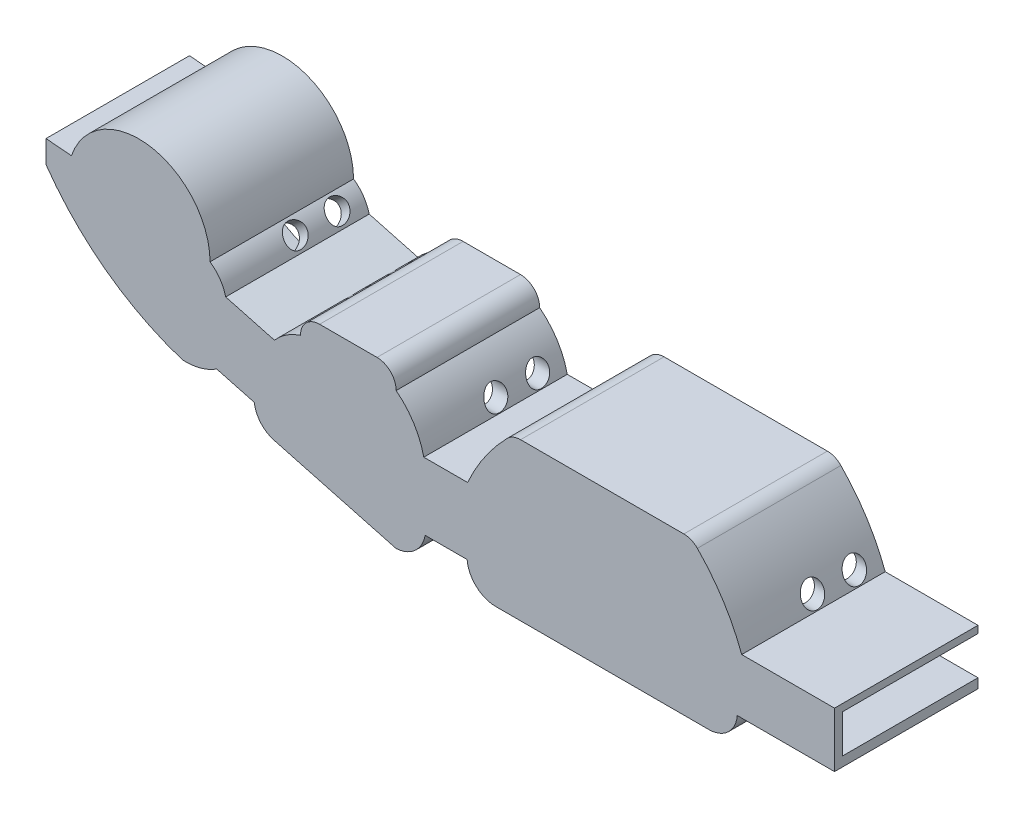
from build123d import *

# Parameters (mm, degrees)
WALLS_DEPTH                         = 16
BASE_DEPTH                          = 1
CUT_EXTRUDE2_REACH                  = 71.681
CUT_EXTRUDE2_END_RADIUS             = 7.978898039
SKETCH14_R                          = 1.4
CUT_EXTRUDE3_REACH                  = 95.244
CUT_EXTRUDE3_END_RADIUS             = 7.978898039
SKETCH15_R                          = 1.4
CUT_EXTRUDE4_REACH                  = 77.904
CUT_EXTRUDE4_END_RADIUS             = 33.443931457
SKETCH16_R                          = 1.4
CUT_EXTRUDE4_DIRECTION_2_REACH      = 77.904
CUT_EXTRUDE4_DIRECTION_2_END_RADIUS = 4.849339701
CUT_EXTRUDE5_REACH                  = 75.034
CUT_EXTRUDE5_END_RADIUS             = 6.135740623
SKETCH18_R                          = 1.4
CUT_EXTRUDE6_DEPTH                  = 1
CUT_EXTRUDE7_START                  = 1
SKETCH20_W                          = 0.5
SKETCH20_H                          = 5.968950485
CUT_EXTRUDE7_DEPTH                  = 13
CUT_EXTRUDE8_START                  = -1
SKETCH21_W                          = 1.2
SKETCH21_H                          = 4.8
CUT_EXTRUDE8_DEPTH                  = 17
BOSS_EXTRUDE7_DEPTH                 = 1


with BuildPart() as part:
    # Sketch1 → Walls (new body)
    with BuildSketch(Plane.XY):
        with BuildLine():
            Line((-89.425677347, 15.217392614), (-89.425677347, 12.385824824))
            ThreePointArc((-89.425677347, 12.385824824), (-81.906348322, 4.663063574), (-72.321084045, -0.266851135))
            ThreePointArc((-72.321084045, -0.266851135), (-70.074490708, -0.03182968), (-68.009952013, 0.884738205))
            Line((-68.009952013, 0.884738205), (-65.712719989, 0.268240269))
            Line((-65.712719989, 0.268240269), (-63.305171624, -0.377862773))
            ThreePointArc((-63.305171624, -0.377862773), (-62.413521198, -2.28542285), (-60.579036899, -3.319102342))
            Line((-60.579036899, -3.319102342), (-45.512163448, -7.362532125))
            ThreePointArc((-45.512163448, -7.362532125), (-43.123330152, -6.369383775), (-41.872204411, -4.104973799))
            Line((-41.872204411, -4.104973799), (-36.601206151, -4.104973799))
            ThreePointArc((-36.601206151, -4.104973799), (-35.453550113, -6.460513587), (-33.012978021, -7.414080542))
            Line((-33.012978021, -7.414080542), (-6.302454756, -7.414080542))
            ThreePointArc((-6.302454756, -7.414080542), (-3.861882663, -6.460513587), (-2.714226626, -4.104973799))
            Line((-2.714226626, -4.104973799), (9.481662569, -4.104973799))
            Line((9.481662569, -4.104973799), (9.481662569, 2.795026201))
            Line((9.481662569, 2.795026201), (-2.157765014, 2.795026201))
            ThreePointArc((-2.157765014, 2.795026201), (-4.475421171, 7.467506564), (-7.720187416, 11.551021571))
            ThreePointArc((-7.720187416, 11.551021571), (-8.494484922, 12.081481284), (-9.414311331, 12.268145448))
            Line((-9.414311331, 12.268145448), (-29.896800773, 12.268145448))
            ThreePointArc((-29.896800773, 12.268145448), (-30.816627182, 12.081481284), (-31.590924688, 11.551021571))
            ThreePointArc((-31.590924688, 11.551021571), (-34.39010211, 8.144207478), (-36.540818273, 4.295026201))
            Line((-36.540818273, 4.295026201), (-42.038103823, 4.295026201))
            ThreePointArc((-42.038103823, 4.295026201), (-43.288812463, 7.352239347), (-45.503987198, 9.802509784))
            ThreePointArc((-45.503987198, 9.802509784), (-46.206930923, 11.499566059), (-47.903987198, 12.202509784))
            Line((-47.903987198, 12.202509784), (-55.103987198, 12.202509784))
            ThreePointArc((-55.103987198, 12.202509784), (-56.801043473, 11.499566059), (-57.503987198, 9.802509784))
            ThreePointArc((-57.503987198, 9.802509784), (-59.284886069, 8.942613092), (-60.772674129, 7.63972791))
            Line((-60.772674129, 7.63972791), (-66.885187578, 9.280115945))
            ThreePointArc((-66.885187578, 9.280115945), (-67.605528448, 10.877592909), (-68.846606478, 12.114746473))
            ThreePointArc((-68.846606478, 12.114746473), (-76.342766302, 20.896236037), (-86.23721729, 14.945873803))
            Line((-86.23721729, 14.945873803), (-89.425677347, 15.217392614))
        make_face()
        with BuildLine():
            Line((-29.957941673, 10.657707986), (-29.654684343, 9.152027))
            Line((-29.654684343, 9.152027), (-29.354684343, 10.652027))
            Line((-29.354684343, 10.652027), (-28.654684343, 10.652027))
            Line((-28.654684343, 10.652027), (-28.354684343, 9.152027))
            Line((-28.354684343, 9.152027), (-28.054684343, 10.652027))
            Line((-28.054684343, 10.652027), (-27.354684343, 10.652027))
            Line((-27.354684343, 10.652027), (-27.054684343, 9.152027))
            Line((-27.054684343, 9.152027), (-26.754684343, 10.652027))
            Line((-26.754684343, 10.652027), (-26.054684343, 10.652027))
            Line((-26.054684343, 10.652027), (-25.754684343, 9.152027))
            Line((-25.754684343, 9.152027), (-25.454684343, 10.652027))
            Line((-25.454684343, 10.652027), (-24.754684343, 10.652027))
            Line((-24.754684343, 10.652027), (-24.454684343, 9.152027))
            Line((-24.454684343, 9.152027), (-24.154684343, 10.652027))
            Line((-24.154684343, 10.652027), (-23.454684343, 10.652027))
            Line((-23.454684343, 10.652027), (-23.154684343, 9.152027))
            Line((-23.154684343, 9.152027), (-22.854684343, 10.652027))
            Line((-22.854684343, 10.652027), (-22.154684343, 10.652027))
            Line((-22.154684343, 10.652027), (-21.854684343, 9.152027))
            Line((-21.854684343, 9.152027), (-21.554684343, 10.652027))
            Line((-21.554684343, 10.652027), (-20.854684343, 10.652027))
            Line((-20.854684343, 10.652027), (-20.554684343, 9.152027))
            Line((-20.554684343, 9.152027), (-20.254684343, 10.652027))
            Line((-20.254684343, 10.652027), (-19.554684343, 10.652027))
            Line((-19.554684343, 10.652027), (-19.254684343, 9.152027))
            Line((-19.254684343, 9.152027), (-18.954684343, 10.652027))
            Line((-18.954684343, 10.652027), (-18.254684343, 10.652027))
            Line((-18.254684343, 10.652027), (-17.954684343, 9.152027))
            Line((-17.954684343, 9.152027), (-17.654684343, 10.652027))
            Line((-17.654684343, 10.652027), (-16.954684343, 10.652027))
            Line((-16.954684343, 10.652027), (-16.654684343, 9.152027))
            Line((-16.654684343, 9.152027), (-16.354684343, 10.652027))
            Line((-16.354684343, 10.652027), (-15.654684343, 10.652027))
            Line((-15.654684343, 10.652027), (-15.354684343, 9.152027))
            Line((-15.354684343, 9.152027), (-15.054684343, 10.652027))
            Line((-15.054684343, 10.652027), (-14.354684343, 10.652027))
            Line((-14.354684343, 10.652027), (-14.054684343, 9.152027))
            Line((-14.054684343, 9.152027), (-13.754684343, 10.652027))
            Line((-13.754684343, 10.652027), (-13.080694354, 10.652027))
            Line((-13.080694354, 10.652027), (-12.780694354, 9.152027))
            Line((-12.780694354, 9.152027), (-12.480694354, 10.652027))
            Line((-12.480694354, 10.652027), (-11.780694354, 10.652027))
            Line((-11.780694354, 10.652027), (-11.480694354, 9.152027))
            Line((-11.480694354, 9.152027), (-11.180694354, 10.652027))
            Line((-11.180694354, 10.652027), (-10.506704364, 10.652027))
            Line((-10.506704364, 10.652027), (-10.206704364, 9.152027))
            Line((-10.206704364, 9.152027), (-9.906704364, 10.652027))
            Line((-9.906704364, 10.652027), (-9.353170431, 10.652027))
            ThreePointArc((-9.353170431, 10.652027), (-8.12308073, 9.896738229), (-7.34300907, 8.682213628))
            ThreePointArc((-7.34300907, 8.682213628), (-4.611558125, 5.76795929), (-3.634781843, 1.895026201))
            Line((-3.634781843, 1.895026201), (8.281662569, 1.895026201))
            Line((8.281662569, 1.895026201), (8.281662569, -2.904973799))
            Line((8.281662569, -2.904973799), (-3.718337431, -2.904973799))
            ThreePointArc((-3.718337431, -2.904973799), (-4.489094638, -5.239633694), (-6.746340048, -6.214080542))
            Line((-6.746340048, -6.214080542), (-32.569092729, -6.214080542))
            ThreePointArc((-32.569092729, -6.214080542), (-34.826338138, -5.239633694), (-35.597095345, -2.904973799))
            Line((-35.597095345, -2.904973799), (-43.623477835, -2.904973799))
            ThreePointArc((-43.623477835, -2.904973799), (-44.552537425, -4.937523747), (-46.570273024, -5.898332815))
            Line((-46.570273024, -5.898332815), (-59.1260009, -2.528807996))
            ThreePointArc((-59.1260009, -2.528807996), (-60.797180114, -1.501489359), (-61.420034751, 0.358692257))
            Line((-61.420034751, 0.358692257), (-69.260670014, 2.462848653))
            ThreePointArc((-69.260670014, 2.462848653), (-70.711197396, 1.000283853), (-72.762994505, 0.817926775))
            ThreePointArc((-72.762994505, 0.817926775), (-79.680116285, 4.137190402), (-85.38669117, 9.26545403))
            Line((-85.38669117, 9.26545403), (-88.684189776, 13.209190532))
            Line((-88.684189776, 13.209190532), (-88.684189776, 13.945331795))
            Line((-88.684189776, 13.945331795), (-88.29851244, 13.504674103))
            Line((-88.29851244, 13.504674103), (-86.640750005, 12.385824824))
            ThreePointArc((-86.640750005, 12.385824824), (-86.238180255, 12.562213326), (-85.831367356, 12.728582111))
            ThreePointArc((-85.831367356, 12.728582111), (-85.245352232, 14.777174034), (-84.141781559, 16.599884754))
            Line((-84.141781559, 16.599884754), (-83.841781559, 15.366152694))
            Line((-83.841781559, 15.366152694), (-83.541781559, 17.266152694))
            ThreePointArc((-83.541781559, 17.266152694), (-83.200039352, 17.586290744), (-82.840238881, 17.88599014))
            Line((-82.840238881, 17.88599014), (-82.540238881, 16.813922832))
            Line((-82.540238881, 16.813922832), (-82.240238881, 18.313922832))
            ThreePointArc((-82.240238881, 18.313922832), (-81.896217932, 18.524190844), (-81.542088231, 18.716947696))
            Line((-81.542088231, 18.716947696), (-81.242088231, 17.693779836))
            Line((-81.242088231, 17.693779836), (-80.942088231, 18.993779836))
            ThreePointArc((-80.942088231, 18.993779836), (-80.595255794, 19.127528905), (-80.2426118, 19.245103414))
            Line((-80.2426118, 19.245103414), (-79.9426118, 18.147652874))
            Line((-79.9426118, 18.147652874), (-79.6426118, 19.404765549))
            ThreePointArc((-79.6426118, 19.404765549), (-79.295091081, 19.474995797), (-78.944811991, 19.529836442))
            Line((-78.944811991, 19.529836442), (-78.644811991, 18.396857922))
            Line((-78.644811991, 18.396857922), (-78.344811991, 19.58746676))
            ThreePointArc((-78.344811991, 19.58746676), (-77.994297473, 19.600247924), (-77.64355905, 19.597729108))
            Line((-77.64355905, 19.597729108), (-77.34355905, 18.457829923))
            Line((-77.34355905, 18.457829923), (-77.04355905, 19.557829923))
            ThreePointArc((-77.04355905, 19.557829923), (-76.692411481, 19.513414143), (-76.34355905, 19.453586402))
            Line((-76.34355905, 19.453586402), (-76.04355905, 18.262977563))
            Line((-76.04355905, 18.262977563), (-75.74355905, 19.312977563))
            ThreePointArc((-75.74355905, 19.312977563), (-75.390953429, 19.207208521), (-75.04355905, 19.085409669))
            Line((-75.04355905, 19.085409669), (-74.74355905, 17.831277439))
            Line((-74.74355905, 17.831277439), (-74.44355905, 18.831277439))
            ThreePointArc((-74.44355905, 18.831277439), (-74.08894338, 18.652985458), (-73.74355905, 18.457409466))
            Line((-73.74355905, 18.457409466), (-73.44355905, 16.960277091))
            Line((-73.44355905, 16.960277091), (-73.14355905, 18.060277091))
            ThreePointArc((-73.14355905, 18.060277091), (-72.78549923, 17.783767154), (-72.44355905, 17.487555249))
            Line((-72.44355905, 17.487555249), (-72.14355905, 15.675519278))
            Line((-72.14355905, 15.675519278), (-71.84355905, 16.875519278))
            ThreePointArc((-71.84355905, 16.875519278), (-71.476987636, 16.427873033), (-71.14355905, 15.955023014))
            Line((-71.14355905, 15.955023014), (-70.84355905, 12.857560784))
            Line((-70.84355905, 12.857560784), (-70.54355905, 14.857560784))
            ThreePointArc((-70.54355905, 14.857560784), (-69.982359005, 13.084494169), (-69.84355905, 11.229920016))
            ThreePointArc((-69.84355905, 11.229920016), (-68.671585206, 9.985898204), (-68.118669602, 8.368679203))
            Line((-68.118669602, 8.368679203), (-60.392067832, 6.295125468))
            ThreePointArc((-60.392067832, 6.295125468), (-59.003259287, 7.752660176), (-57.217446594, 8.682213628))
            ThreePointArc((-57.217446594, 8.682213628), (-56.631660156, 10.096427191), (-55.217446594, 10.682213628))
            Line((-55.217446594, 10.682213628), (-55.133592914, 10.682178618))
            Line((-55.133592914, 10.682178618), (-54.833592914, 9.182178618))
            Line((-54.833592914, 9.182178618), (-54.533592914, 10.682178618))
            Line((-54.533592914, 10.682178618), (-53.833592914, 10.682178618))
            Line((-53.833592914, 10.682178618), (-53.533592914, 9.182178618))
            Line((-53.533592914, 9.182178618), (-53.233592914, 10.682178618))
            Line((-53.233592914, 10.682178618), (-52.533592914, 10.682178618))
            Line((-52.533592914, 10.682178618), (-52.233592914, 9.182178618))
            Line((-52.233592914, 9.182178618), (-51.933592914, 10.682178618))
            Line((-51.933592914, 10.682178618), (-51.259602924, 10.682178618))
            Line((-51.259602924, 10.682178618), (-50.959602924, 9.182178618))
            Line((-50.959602924, 9.182178618), (-50.659602924, 10.682178618))
            Line((-50.659602924, 10.682178618), (-49.959602924, 10.682178618))
            Line((-49.959602924, 10.682178618), (-49.659602924, 9.182178618))
            Line((-49.659602924, 9.182178618), (-49.359602924, 10.682178618))
            Line((-49.359602924, 10.682178618), (-49.217446594, 10.682213628))
            ThreePointArc((-49.217446594, 10.682213628), (-47.803233031, 10.096427191), (-47.217446594, 8.682213628))
            ThreePointArc((-47.217446594, 8.682213628), (-44.794291294, 6.284887251), (-43.592774814, 3.095026201))
            Line((-43.592774814, 3.095026201), (-35.592774814, 3.095026201))
            ThreePointArc((-35.592774814, 3.095026201), (-34.391258334, 6.284887251), (-31.968103034, 8.682213628))
            ThreePointArc((-31.968103034, 8.682213628), (-31.843038743, 9.372290059), (-31.483754411, 9.974586769))
            ThreePointArc((-31.483754411, 9.974586769), (-30.795920105, 10.483827589), (-29.957941673, 10.657707986))
        make_face(mode=Mode.SUBTRACT)
    extrude(amount=WALLS_DEPTH)

    # Sketch2 → Base (add)
    with BuildSketch(Plane(origin=(0, 0, 0), x_dir=(-1, 0, 0), z_dir=(0, 0, -1))):
        with BuildLine():
            Line((66.885187578, 9.280115945), (60.772674129, 7.63972791))
            ThreePointArc((60.772674129, 7.63972791), (59.284886069, 8.942613092), (57.503987198, 9.802509784))
            ThreePointArc((57.503987198, 9.802509784), (56.801043473, 11.499566059), (55.103987198, 12.202509784))
            Line((55.103987198, 12.202509784), (47.903987198, 12.202509784))
            ThreePointArc((47.903987198, 12.202509784), (46.206930923, 11.499566059), (45.503987198, 9.802509784))
            ThreePointArc((45.503987198, 9.802509784), (43.288812463, 7.352239347), (42.038103823, 4.295026201))
            Line((42.038103823, 4.295026201), (36.540818273, 4.295026201))
            ThreePointArc((36.540818273, 4.295026201), (34.39010211, 8.144207478), (31.590924688, 11.551021571))
            ThreePointArc((31.590924688, 11.551021571), (30.816627182, 12.081481284), (29.896800773, 12.268145448))
            Line((29.896800773, 12.268145448), (9.414311331, 12.268145448))
            ThreePointArc((9.414311331, 12.268145448), (8.494484922, 12.081481284), (7.720187416, 11.551021571))
            ThreePointArc((7.720187416, 11.551021571), (4.475421171, 7.467506564), (2.157765014, 2.795026201))
            Line((2.157765014, 2.795026201), (-9.481662569, 2.795026201))
            Line((-9.481662569, 2.795026201), (-9.481662569, -4.104973799))
            Line((-9.481662569, -4.104973799), (2.714226626, -4.104973799))
            ThreePointArc((2.714226626, -4.104973799), (3.861882663, -6.460513587), (6.302454756, -7.414080542))
            Line((6.302454756, -7.414080542), (33.012978021, -7.414080542))
            ThreePointArc((33.012978021, -7.414080542), (35.453550113, -6.460513587), (36.601206151, -4.104973799))
            Line((36.601206151, -4.104973799), (41.872204411, -4.104973799))
            ThreePointArc((41.872204411, -4.104973799), (43.123330152, -6.369383775), (45.512163448, -7.362532125))
            Line((45.512163448, -7.362532125), (60.579036899, -3.319102342))
            ThreePointArc((60.579036899, -3.319102342), (62.413521198, -2.28542285), (63.305171624, -0.377862773))
            Line((63.305171624, -0.377862773), (68.009952013, 0.884738205))
            ThreePointArc((68.009952013, 0.884738205), (70.074490708, -0.03182968), (72.321084045, -0.266851135))
            ThreePointArc((72.321084045, -0.266851135), (81.906348322, 4.663063574), (89.425677347, 12.385824824))
            Line((89.425677347, 12.385824824), (89.425677347, 15.217392614))
            Line((89.425677347, 15.217392614), (86.23721729, 14.945873803))
            ThreePointArc((86.23721729, 14.945873803), (76.342766302, 20.896236037), (68.846606478, 12.114746473))
            ThreePointArc((68.846606478, 12.114746473), (67.605528448, 10.877592909), (66.885187578, 9.280115945))
        make_face()
    extrude(amount=BASE_DEPTH)

    # Cut-Extrude2: up to this cylinder (the profile starts outside it)
    cut_extrude2_end = Plane(origin=(-27.697572731, 1.942377959, 4.875), z_dir=(0, 0, -1)) * Cylinder(CUT_EXTRUDE2_END_RADIUS, 165.569796077, mode=Mode.PRIVATE)
    # Sketch14 → Cut-Extrude2 (cut, up to the surface)
    with BuildSketch(Plane(origin=(-55, 0, 0), x_dir=(0, 0, -1), z_dir=(1, 0, 0)), mode=Mode.PRIVATE) as cut_extrude2_sk1:
        with Locations(Location((-2.25, 5.771124661, 0), (0, 0, 180))):
            Circle(SKETCH14_R)
    cut_extrude2_tool1 = extrude(cut_extrude2_sk1.sketch, amount=CUT_EXTRUDE2_REACH, mode=Mode.PRIVATE) - cut_extrude2_end
    add(cut_extrude2_tool1.solids().sort_by_distance((-55, 5.771125, 2.25))[0], mode=Mode.SUBTRACT)
    # Sketch14 → Cut-Extrude2 (cut, up to the surface)
    with BuildSketch(Plane(origin=(-55, 0, 0), x_dir=(0, 0, -1), z_dir=(1, 0, 0)), mode=Mode.PRIVATE) as cut_extrude2_sk2:
        with Locations(Location((-7.5, 5.771124661, 0), (0, 0, 180))):
            Circle(SKETCH14_R)
    cut_extrude2_tool2 = extrude(cut_extrude2_sk2.sketch, amount=CUT_EXTRUDE2_REACH, mode=Mode.PRIVATE) - cut_extrude2_end
    add(cut_extrude2_tool2.solids().sort_by_distance((-55, 5.771125, 7.5))[0], mode=Mode.SUBTRACT)

    # Cut-Extrude3: up to this cylinder (the profile starts outside it)
    cut_extrude3_end = Plane(origin=(-11.613539373, 1.942377959, 4.875), z_dir=(0, 0, -1)) * Cylinder(CUT_EXTRUDE3_END_RADIUS, 212.695796077, mode=Mode.PRIVATE)
    # Sketch15 → Cut-Extrude3 (cut, up to the surface)
    with BuildSketch(Plane(origin=(0, 0, 0), x_dir=(0, 0, -1), z_dir=(1, 0, 0)), mode=Mode.PRIVATE) as cut_extrude3_sk1:
        with Locations((-2.25, 4.295026201)):
            Circle(SKETCH15_R)
    cut_extrude3_tool1 = extrude(cut_extrude3_sk1.sketch, amount=-CUT_EXTRUDE3_REACH, mode=Mode.PRIVATE) - cut_extrude3_end
    add(cut_extrude3_tool1.solids().sort_by_distance((0, 4.295026, 2.25))[0], mode=Mode.SUBTRACT)
    # Sketch15 → Cut-Extrude3 (cut, up to the surface)
    with BuildSketch(Plane(origin=(0, 0, 0), x_dir=(0, 0, -1), z_dir=(1, 0, 0)), mode=Mode.PRIVATE) as cut_extrude3_sk2:
        with Locations((-7.5, 4.295026201)):
            Circle(SKETCH15_R)
    cut_extrude3_tool2 = extrude(cut_extrude3_sk2.sketch, amount=-CUT_EXTRUDE3_REACH, mode=Mode.PRIVATE) - cut_extrude3_end
    add(cut_extrude3_tool2.solids().sort_by_distance((0, 4.295026, 7.5))[0], mode=Mode.SUBTRACT)

    # Cut-Extrude4: up to this cylinder (the profile starts inside it)
    cut_extrude4_end = Plane(origin=(-62.017257268, 31.550246549, 4.875), z_dir=(0, 0, -1)) * Cylinder(CUT_EXTRUDE4_END_RADIUS, 228.945862914, mode=Mode.PRIVATE)
    # Sketch16 → Cut-Extrude4 (cut, up to the surface)
    with BuildSketch(Plane(origin=(-34.706485046, -29.099233606, 0), x_dir=(0, 0, -1), z_dir=(0.7662940611199278, 0.642490009177052, 0)), mode=Mode.PRIVATE) as cut_extrude4_sk1:
        with Locations(Location((-2.25, 51.800538809, 0), (0, 0, 90))):
            Circle(SKETCH16_R)
    cut_extrude4_tool1 = extrude(cut_extrude4_sk1.sketch, amount=-CUT_EXTRUDE4_REACH, mode=Mode.PRIVATE) & cut_extrude4_end
    add(cut_extrude4_tool1.solids().sort_by_distance((-67.987814, 10.595212, 2.25))[0], mode=Mode.SUBTRACT)
    # Sketch16 → Cut-Extrude4 (cut, up to the surface)
    with BuildSketch(Plane(origin=(-34.706485046, -29.099233606, 0), x_dir=(0, 0, -1), z_dir=(0.7662940611199278, 0.642490009177052, 0)), mode=Mode.PRIVATE) as cut_extrude4_sk2:
        with Locations(Location((-7.5, 51.800538809, 0), (0, 0, 90))):
            Circle(SKETCH16_R)
    cut_extrude4_tool2 = extrude(cut_extrude4_sk2.sketch, amount=-CUT_EXTRUDE4_REACH, mode=Mode.PRIVATE) & cut_extrude4_end
    add(cut_extrude4_tool2.solids().sort_by_distance((-67.987814, 10.595212, 7.5))[0], mode=Mode.SUBTRACT)

    # Cut-Extrude4 direction 2: up to this cylinder (the profile starts inside it)
    cut_extrude4_direction_2_end = Plane(origin=(-71.59328755, 8.118268196, 4.875), z_dir=(0, 0, -1)) * Cylinder(CUT_EXTRUDE4_DIRECTION_2_END_RADIUS, 171.756679402, mode=Mode.PRIVATE)
    # Sketch16 → Cut-Extrude4 direction 2 (cut, up to the surface)
    with BuildSketch(Plane(origin=(-34.706485046, -29.099233606, 0), x_dir=(0, 0, -1), z_dir=(0.7662940611199278, 0.642490009177052, 0)), mode=Mode.PRIVATE) as cut_extrude4_direction_2_sk1:
        with Locations(Location((-2.25, 51.800538809, 0), (0, 0, 90))):
            Circle(SKETCH16_R)
    cut_extrude4_direction_2_tool1 = extrude(cut_extrude4_direction_2_sk1.sketch, amount=CUT_EXTRUDE4_DIRECTION_2_REACH, mode=Mode.PRIVATE) & cut_extrude4_direction_2_end
    add(cut_extrude4_direction_2_tool1.solids().sort_by_distance((-67.987814, 10.595212, 2.25))[0], mode=Mode.SUBTRACT)
    # Sketch16 → Cut-Extrude4 direction 2 (cut, up to the surface)
    with BuildSketch(Plane(origin=(-34.706485046, -29.099233606, 0), x_dir=(0, 0, -1), z_dir=(0.7662940611199278, 0.642490009177052, 0)), mode=Mode.PRIVATE) as cut_extrude4_direction_2_sk2:
        with Locations(Location((-7.5, 51.800538809, 0), (0, 0, 90))):
            Circle(SKETCH16_R)
    cut_extrude4_direction_2_tool2 = extrude(cut_extrude4_direction_2_sk2.sketch, amount=CUT_EXTRUDE4_DIRECTION_2_REACH, mode=Mode.PRIVATE) & cut_extrude4_direction_2_end
    add(cut_extrude4_direction_2_tool2.solids().sort_by_distance((-67.987814, 10.595212, 7.5))[0], mode=Mode.SUBTRACT)

    # Cut-Extrude5: up to this cylinder (the profile starts outside it)
    cut_extrude5_end = Plane(origin=(-55.315764964, 2.84861097, 4.875), z_dir=(0, 0, -1)) * Cylinder(CUT_EXTRUDE5_END_RADIUS, 168.589481246, mode=Mode.PRIVATE)
    # Sketch18 → Cut-Extrude5 (cut, up to the surface)
    with BuildSketch(Plane(origin=(-56.106074928, 20.445624842, 0), x_dir=(0, 0, -1), z_dir=(-0.9395597001849875, 0.3423851191104788, 0)), mode=Mode.PRIVATE) as cut_extrude5_sk1:
        with Locations(Location((-2.25, 12.178466352, 0), (0, 0, 90))):
            Circle(SKETCH18_R)
    cut_extrude5_tool1 = extrude(cut_extrude5_sk1.sketch, amount=-CUT_EXTRUDE5_REACH, mode=Mode.PRIVATE) - cut_extrude5_end
    add(cut_extrude5_tool1.solids().sort_by_distance((-60.275801, 9.003229, 2.25))[0], mode=Mode.SUBTRACT)
    # Sketch18 → Cut-Extrude5 (cut, up to the surface)
    with BuildSketch(Plane(origin=(-56.106074928, 20.445624842, 0), x_dir=(0, 0, -1), z_dir=(-0.9395597001849875, 0.3423851191104788, 0)), mode=Mode.PRIVATE) as cut_extrude5_sk2:
        with Locations(Location((-7.5, 12.178466352, 0), (0, 0, 90))):
            Circle(SKETCH18_R)
    cut_extrude5_tool2 = extrude(cut_extrude5_sk2.sketch, amount=-CUT_EXTRUDE5_REACH, mode=Mode.PRIVATE) - cut_extrude5_end
    add(cut_extrude5_tool2.solids().sort_by_distance((-60.275801, 9.003229, 7.5))[0], mode=Mode.SUBTRACT)

    # Sketch19 → Cut-Extrude6 (cut)
    with BuildSketch(Plane.XY):
        with BuildLine():
            Line((-12.780694354, 9.152027), (-13.080694354, 10.652027))
            Line((-13.080694354, 10.652027), (-13.754684343, 10.652027))
            Line((-13.754684343, 10.652027), (-14.054684343, 9.152027))
            Line((-14.054684343, 9.152027), (-14.354684343, 10.652027))
            Line((-14.354684343, 10.652027), (-15.054684343, 10.652027))
            Line((-15.054684343, 10.652027), (-15.354684343, 9.152027))
            Line((-15.354684343, 9.152027), (-15.654684343, 10.652027))
            Line((-15.654684343, 10.652027), (-16.354684343, 10.652027))
            Line((-16.354684343, 10.652027), (-16.654684343, 9.152027))
            Line((-16.654684343, 9.152027), (-16.954684343, 10.652027))
            Line((-16.954684343, 10.652027), (-17.654684343, 10.652027))
            Line((-17.654684343, 10.652027), (-17.954684343, 9.152027))
            Line((-17.954684343, 9.152027), (-18.254684343, 10.652027))
            Line((-18.254684343, 10.652027), (-18.954684343, 10.652027))
            Line((-18.954684343, 10.652027), (-19.254684343, 9.152027))
            Line((-19.254684343, 9.152027), (-19.554684343, 10.652027))
            Line((-19.554684343, 10.652027), (-20.254684343, 10.652027))
            Line((-20.254684343, 10.652027), (-20.554684343, 9.152027))
            Line((-20.554684343, 9.152027), (-20.854684343, 10.652027))
            Line((-20.854684343, 10.652027), (-21.554684343, 10.652027))
            Line((-21.554684343, 10.652027), (-21.854684343, 9.152027))
            Line((-21.854684343, 9.152027), (-22.154684343, 10.652027))
            Line((-22.154684343, 10.652027), (-22.854684343, 10.652027))
            Line((-22.854684343, 10.652027), (-23.154684343, 9.152027))
            Line((-23.154684343, 9.152027), (-23.454684343, 10.652027))
            Line((-23.454684343, 10.652027), (-24.154684343, 10.652027))
            Line((-24.154684343, 10.652027), (-24.454684343, 9.152027))
            Line((-24.454684343, 9.152027), (-24.754684343, 10.652027))
            Line((-24.754684343, 10.652027), (-25.454684343, 10.652027))
            Line((-25.454684343, 10.652027), (-25.754684343, 9.152027))
            Line((-25.754684343, 9.152027), (-26.054684343, 10.652027))
            Line((-26.054684343, 10.652027), (-26.754684343, 10.652027))
            Line((-26.754684343, 10.652027), (-27.054684343, 9.152027))
            Line((-27.054684343, 9.152027), (-27.354684343, 10.652027))
            Line((-27.354684343, 10.652027), (-28.054684343, 10.652027))
            Line((-28.054684343, 10.652027), (-28.354684343, 9.152027))
            Line((-28.354684343, 9.152027), (-28.654684343, 10.652027))
            Line((-28.654684343, 10.652027), (-29.354684343, 10.652027))
            Line((-29.354684343, 10.652027), (-29.654684343, 9.152027))
            Line((-29.654684343, 9.152027), (-29.957941673, 10.657707986))
            ThreePointArc((-29.957941673, 10.657707986), (-30.795920105, 10.483827589), (-31.483754411, 9.974586769))
            ThreePointArc((-31.483754411, 9.974586769), (-31.843038743, 9.372290059), (-31.968103034, 8.682213628))
            ThreePointArc((-31.968103034, 8.682213628), (-34.391258334, 6.284887251), (-35.592774814, 3.095026201))
            Line((-35.592774814, 3.095026201), (-43.592774814, 3.095026201))
            ThreePointArc((-43.592774814, 3.095026201), (-44.794291294, 6.284887251), (-47.217446594, 8.682213628))
            ThreePointArc((-47.217446594, 8.682213628), (-47.803233031, 10.096427191), (-49.217446594, 10.682213628))
            Line((-49.217446594, 10.682213628), (-49.359602924, 10.682178618))
            Line((-49.359602924, 10.682178618), (-49.659602924, 9.182178618))
            Line((-49.659602924, 9.182178618), (-49.959602924, 10.682178618))
            Line((-49.959602924, 10.682178618), (-50.659602924, 10.682178618))
            Line((-50.659602924, 10.682178618), (-50.959602924, 9.182178618))
            Line((-50.959602924, 9.182178618), (-51.259602924, 10.682178618))
            Line((-51.259602924, 10.682178618), (-51.933592914, 10.682178618))
            Line((-51.933592914, 10.682178618), (-52.233592914, 9.182178618))
            Line((-52.233592914, 9.182178618), (-52.533592914, 10.682178618))
            Line((-52.533592914, 10.682178618), (-53.233592914, 10.682178618))
            Line((-53.233592914, 10.682178618), (-53.533592914, 9.182178618))
            Line((-53.533592914, 9.182178618), (-53.833592914, 10.682178618))
            Line((-53.833592914, 10.682178618), (-54.533592914, 10.682178618))
            Line((-54.533592914, 10.682178618), (-54.833592914, 9.182178618))
            Line((-54.833592914, 9.182178618), (-55.133592914, 10.682178618))
            Line((-55.133592914, 10.682178618), (-55.217446594, 10.682213628))
            ThreePointArc((-55.217446594, 10.682213628), (-56.631660156, 10.096427191), (-57.217446594, 8.682213628))
            ThreePointArc((-57.217446594, 8.682213628), (-59.003259287, 7.752660176), (-60.392067832, 6.295125468))
            Line((-60.392067832, 6.295125468), (-68.118669602, 8.368679203))
            ThreePointArc((-68.118669602, 8.368679203), (-68.671585206, 9.985898204), (-69.84355905, 11.229920016))
            ThreePointArc((-69.84355905, 11.229920016), (-69.982359005, 13.084494169), (-70.54355905, 14.857560784))
            Line((-70.54355905, 14.857560784), (-70.84355905, 12.857560784))
            Line((-70.84355905, 12.857560784), (-71.14355905, 15.955023014))
            ThreePointArc((-71.14355905, 15.955023014), (-71.476987636, 16.427873033), (-71.84355905, 16.875519278))
            Line((-71.84355905, 16.875519278), (-72.14355905, 15.675519278))
            Line((-72.14355905, 15.675519278), (-72.44355905, 17.487555249))
            ThreePointArc((-72.44355905, 17.487555249), (-72.78549923, 17.783767154), (-73.14355905, 18.060277091))
            Line((-73.14355905, 18.060277091), (-73.44355905, 16.960277091))
            Line((-73.44355905, 16.960277091), (-73.74355905, 18.457409466))
            ThreePointArc((-73.74355905, 18.457409466), (-74.08894338, 18.652985458), (-74.44355905, 18.831277439))
            Line((-74.44355905, 18.831277439), (-74.74355905, 17.831277439))
            Line((-74.74355905, 17.831277439), (-75.04355905, 19.085409669))
            ThreePointArc((-75.04355905, 19.085409669), (-75.390953429, 19.207208521), (-75.74355905, 19.312977563))
            Line((-75.74355905, 19.312977563), (-76.04355905, 18.262977563))
            Line((-76.04355905, 18.262977563), (-76.34355905, 19.453586402))
            ThreePointArc((-76.34355905, 19.453586402), (-76.692411481, 19.513414143), (-77.04355905, 19.557829923))
            Line((-77.04355905, 19.557829923), (-77.34355905, 18.457829923))
            Line((-77.34355905, 18.457829923), (-77.64355905, 19.597729108))
            ThreePointArc((-77.64355905, 19.597729108), (-77.994297473, 19.600247924), (-78.344811991, 19.58746676))
            Line((-78.344811991, 19.58746676), (-78.644811991, 18.396857922))
            Line((-78.644811991, 18.396857922), (-78.944811991, 19.529836442))
            ThreePointArc((-78.944811991, 19.529836442), (-79.295091081, 19.474995797), (-79.6426118, 19.404765549))
            Line((-79.6426118, 19.404765549), (-79.9426118, 18.147652874))
            Line((-79.9426118, 18.147652874), (-80.2426118, 19.245103414))
            ThreePointArc((-80.2426118, 19.245103414), (-80.595255794, 19.127528905), (-80.942088231, 18.993779836))
            Line((-80.942088231, 18.993779836), (-81.242088231, 17.693779836))
            Line((-81.242088231, 17.693779836), (-81.542088231, 18.716947696))
            ThreePointArc((-81.542088231, 18.716947696), (-81.896217932, 18.524190844), (-82.240238881, 18.313922832))
            Line((-82.240238881, 18.313922832), (-82.540238881, 16.813922832))
            Line((-82.540238881, 16.813922832), (-82.840238881, 17.885990141))
            ThreePointArc((-82.840238881, 17.885990141), (-83.200039352, 17.586290744), (-83.541781559, 17.266152694))
            Line((-83.541781559, 17.266152694), (-83.841781559, 15.366152694))
            Line((-83.841781559, 15.366152694), (-84.141781559, 16.599884754))
            ThreePointArc((-84.141781559, 16.599884754), (-85.245352232, 14.777174035), (-85.831367356, 12.728582111))
            ThreePointArc((-85.831367356, 12.728582111), (-86.238180255, 12.562213326), (-86.640750005, 12.385824824))
            Line((-86.640750005, 12.385824824), (-88.29851244, 13.504674103))
            Line((-88.29851244, 13.504674103), (-88.684189776, 13.945331795))
            Line((-88.684189776, 13.945331795), (-88.684189776, 13.209190532))
            Line((-88.684189776, 13.209190532), (-85.38669117, 9.26545403))
            ThreePointArc((-85.38669117, 9.26545403), (-79.680116285, 4.137190402), (-72.762994505, 0.817926775))
            ThreePointArc((-72.762994505, 0.817926775), (-70.711197396, 1.000283853), (-69.260670014, 2.462848653))
            Line((-69.260670014, 2.462848653), (-61.420034751, 0.358692257))
            ThreePointArc((-61.420034751, 0.358692257), (-60.797180114, -1.501489359), (-59.1260009, -2.528807996))
            Line((-59.1260009, -2.528807996), (-46.570273024, -5.898332815))
            ThreePointArc((-46.570273024, -5.898332815), (-44.552537425, -4.937523747), (-43.623477835, -2.904973799))
            Line((-43.623477835, -2.904973799), (-35.597095345, -2.904973799))
            ThreePointArc((-35.597095345, -2.904973799), (-34.826338138, -5.239633694), (-32.569092729, -6.214080542))
            Line((-32.569092729, -6.214080542), (-6.746340048, -6.214080542))
            ThreePointArc((-6.746340048, -6.214080542), (-4.489094638, -5.239633694), (-3.718337431, -2.904973799))
            Line((-3.718337431, -2.904973799), (8.281662569, -2.904973799))
            Line((8.281662569, -2.904973799), (8.281662569, 1.895026201))
            Line((8.281662569, 1.895026201), (-3.634781843, 1.895026201))
            ThreePointArc((-3.634781843, 1.895026201), (-4.611558125, 5.76795929), (-7.34300907, 8.682213628))
            ThreePointArc((-7.34300907, 8.682213628), (-8.12308073, 9.896738229), (-9.353170431, 10.652027))
            Line((-9.353170431, 10.652027), (-9.906704364, 10.652027))
            Line((-9.906704364, 10.652027), (-10.206704364, 9.152027))
            Line((-10.206704364, 9.152027), (-10.506704364, 10.652027))
            Line((-10.506704364, 10.652027), (-11.180694354, 10.652027))
            Line((-11.180694354, 10.652027), (-11.480694354, 9.152027))
            Line((-11.480694354, 9.152027), (-11.780694354, 10.652027))
            Line((-11.780694354, 10.652027), (-12.480694354, 10.652027))
            Line((-12.480694354, 10.652027), (-12.780694354, 9.152027))
        make_face()
    extrude(amount=-CUT_EXTRUDE6_DEPTH, mode=Mode.SUBTRACT)

    # Sketch20 → Cut-Extrude7 (cut)
    with BuildSketch(Plane.XY.offset(CUT_EXTRUDE7_START)):
        Polygon((-86.479271747, 6.011586265), (-84.000305026, 8.428703375), (-83.666034878, 8.05629214), (-86.130212458, 5.653595186), align=None)
        Polygon((-53.39190443, -6.239789746), (-52.304369495, -2.187351066), (-51.821456884, -2.316948174), (-52.90899182, -6.369386854), align=None)
        Polygon((-74.75878615, 2.18354453), (-75.790367789, -0.551879915), (-75.322529992, -0.728310627), (-74.290948353, 2.007113819), align=None)
        with Locations((-24.497959011, -7.165975116)):
            Rectangle(SKETCH20_W, SKETCH20_H)
    extrude(amount=CUT_EXTRUDE7_DEPTH, mode=Mode.SUBTRACT)

    # Sketch21 → Cut-Extrude8 (cut)
    with BuildSketch(Plane.XY.offset(CUT_EXTRUDE8_START)):
        with Locations((8.881662569, -0.504973799)):
            Rectangle(SKETCH21_W, SKETCH21_H)
    extrude(amount=CUT_EXTRUDE8_DEPTH, mode=Mode.SUBTRACT)

    # Sketch22 → Boss-Extrude7 (add)
    with BuildSketch(Plane.XY.offset(16)):
        with BuildLine():
            Line((-89.425677347, 15.217392614), (-86.23721729, 14.945873803))
            ThreePointArc((-86.23721729, 14.945873803), (-76.342766302, 20.896236037), (-68.846606478, 12.114746473))
            ThreePointArc((-68.846606478, 12.114746473), (-67.605528448, 10.877592909), (-66.885187578, 9.280115945))
            Line((-66.885187578, 9.280115945), (-60.772674129, 7.63972791))
            ThreePointArc((-60.772674129, 7.63972791), (-59.284886069, 8.942613092), (-57.503987198, 9.802509784))
            ThreePointArc((-57.503987198, 9.802509784), (-56.801043473, 11.499566059), (-55.103987198, 12.202509784))
            Line((-55.103987198, 12.202509784), (-47.903987198, 12.202509784))
            ThreePointArc((-47.903987198, 12.202509784), (-46.206930923, 11.499566059), (-45.503987198, 9.802509784))
            ThreePointArc((-45.503987198, 9.802509784), (-43.288812463, 7.352239347), (-42.038103823, 4.295026201))
            Line((-42.038103823, 4.295026201), (-36.540818273, 4.295026201))
            ThreePointArc((-36.540818273, 4.295026201), (-34.39010211, 8.144207478), (-31.590924688, 11.551021571))
            ThreePointArc((-31.590924688, 11.551021571), (-30.816627182, 12.081481284), (-29.896800773, 12.268145448))
            Line((-29.896800773, 12.268145448), (-9.414311331, 12.268145448))
            ThreePointArc((-9.414311331, 12.268145448), (-8.494484922, 12.081481284), (-7.720187416, 11.551021571))
            ThreePointArc((-7.720187416, 11.551021571), (-4.475421171, 7.467506564), (-2.157765014, 2.795026201))
            Line((-2.157765014, 2.795026201), (9.481662569, 2.795026201))
            Line((9.481662569, 2.795026201), (9.481662569, -4.104973799))
            Line((9.481662569, -4.104973799), (-2.714226626, -4.104973799))
            ThreePointArc((-2.714226626, -4.104973799), (-3.861882663, -6.460513587), (-6.302454756, -7.414080542))
            Line((-6.302454756, -7.414080542), (-33.012978021, -7.414080542))
            ThreePointArc((-33.012978021, -7.414080542), (-35.453550113, -6.460513587), (-36.601206151, -4.104973799))
            Line((-36.601206151, -4.104973799), (-41.872204411, -4.104973799))
            ThreePointArc((-41.872204411, -4.104973799), (-43.123330152, -6.369383775), (-45.512163448, -7.362532125))
            Line((-45.512163448, -7.362532125), (-60.579036899, -3.319102342))
            ThreePointArc((-60.579036899, -3.319102342), (-62.413521198, -2.28542285), (-63.305171624, -0.377862773))
            Line((-63.305171624, -0.377862773), (-65.712719989, 0.268240269))
            Line((-65.712719989, 0.268240269), (-68.009952013, 0.884738205))
            ThreePointArc((-68.009952013, 0.884738205), (-70.074490708, -0.03182968), (-72.321084045, -0.266851135))
            ThreePointArc((-72.321084045, -0.266851135), (-81.906348322, 4.663063574), (-89.425677347, 12.385824824))
            Line((-89.425677347, 12.385824824), (-89.425677347, 15.217392614))
        make_face()
    extrude(amount=BOSS_EXTRUDE7_DEPTH)


solid = part.part
